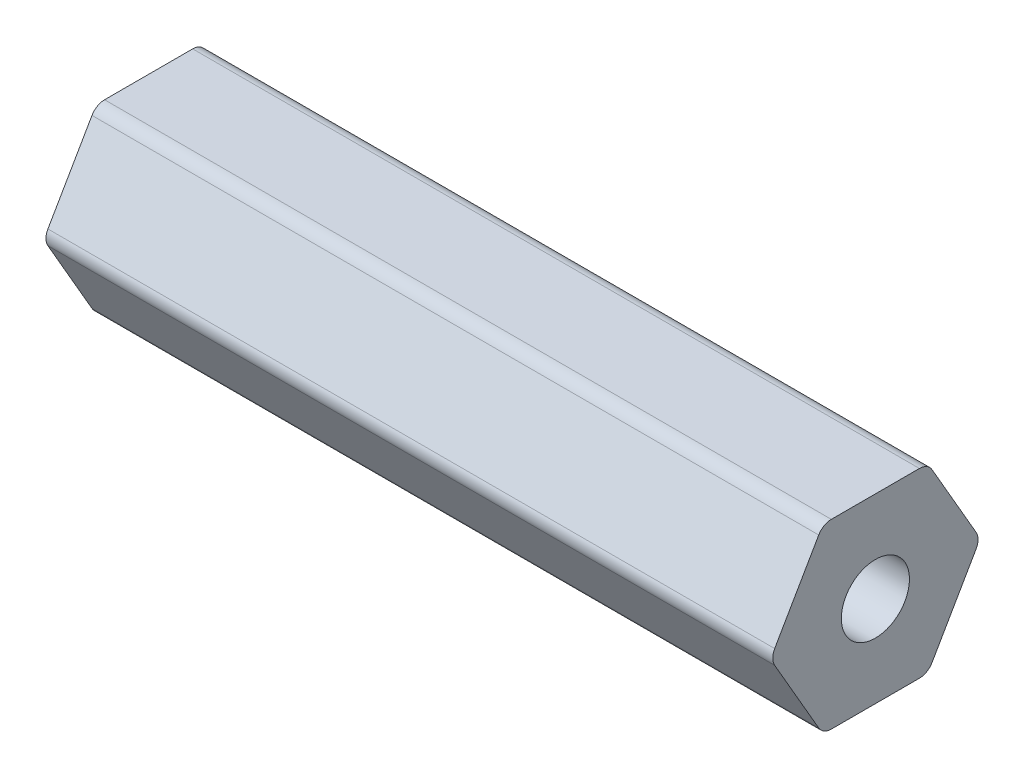
from build123d import *

# Parameters (mm, degrees)
SKETCH1_R           = 2.38125
BOSS_EXTRUDE1_DEPTH = 50.8


with BuildPart() as part:
    # Sketch1 → Boss-Extrude1 (new body)
    with BuildSketch(Plane(origin=(0, 0, 0), x_dir=(0, 0, -1), z_dir=(1, 0, 0))):
        with BuildLine():
            Line((7.039054482, 0.508), (3.959468146, 5.842))
            ThreePointArc((3.959468146, 5.842), (3.587586336, 6.21388181), (3.079586336, 6.35))
            Line((3.079586336, 6.35), (-3.079586336, 6.35))
            ThreePointArc((-3.079586336, 6.35), (-3.587586336, 6.21388181), (-3.959468146, 5.842))
            Line((-3.959468146, 5.842), (-7.039054482, 0.508))
            ThreePointArc((-7.039054482, 0.508), (-7.175172672, 0), (-7.039054482, -0.508))
            Line((-7.039054482, -0.508), (-3.959468146, -5.842))
            ThreePointArc((-3.959468146, -5.842), (-3.587586336, -6.21388181), (-3.079586336, -6.35))
            Line((-3.079586336, -6.35), (3.079586336, -6.35))
            ThreePointArc((3.079586336, -6.35), (3.587586336, -6.21388181), (3.959468146, -5.842))
            Line((3.959468146, -5.842), (7.039054482, -0.508))
            ThreePointArc((7.039054482, -0.508), (7.175172672, 0), (7.039054482, 0.508))
        make_face()
        Circle(SKETCH1_R, mode=Mode.SUBTRACT)
    extrude(amount=BOSS_EXTRUDE1_DEPTH)


solid = part.part
